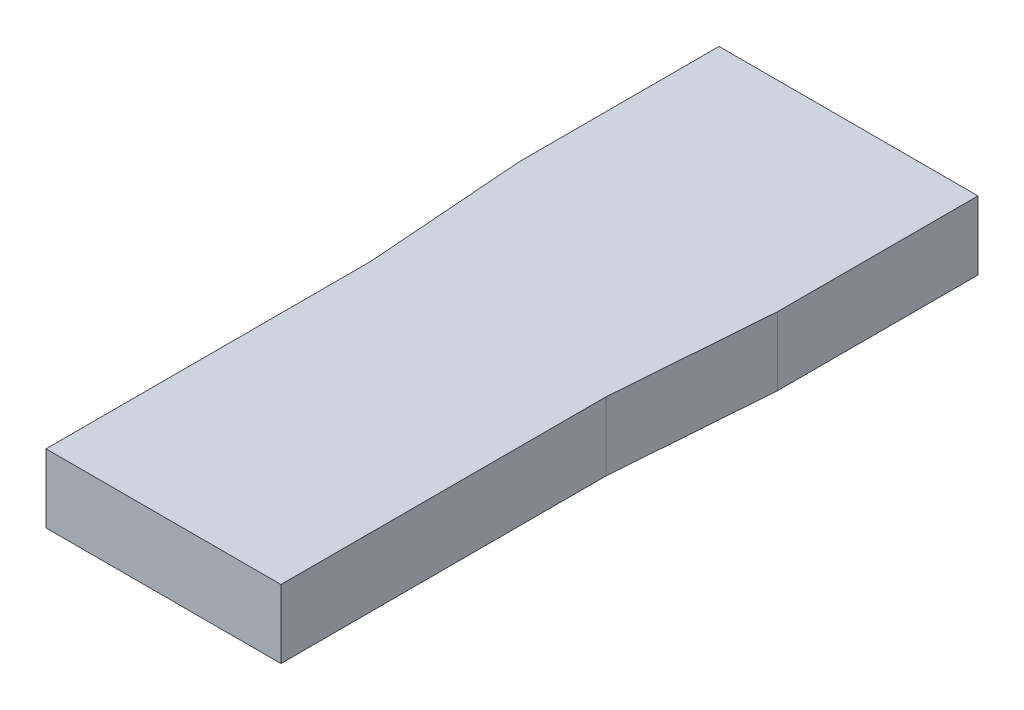
from build123d import *

# Parameters (mm, degrees)
SKETCH1_W           = 11.34
SKETCH1_H           = 30
BOSS_EXTRUDE1_DEPTH = 3
CUT_EXTRUDE1_START  = -4
CUT_EXTRUDE1_DEPTH  = 5


with BuildPart() as part:
    # Sketch1 → Boss-Extrude1 (new body)
    with BuildSketch(Plane(origin=(0, 0, 0), x_dir=(1, 0, 0), z_dir=(0, 1, 0))):
        Rectangle(SKETCH1_W, SKETCH1_H)
    extrude(amount=BOSS_EXTRUDE1_DEPTH)

    # Sketch2 → Cut-Extrude1 (cut)
    with BuildSketch(Plane(origin=(0, 3, 0), x_dir=(1, 0, 0), z_dir=(0, 1, 0)).offset(CUT_EXTRUDE1_START)):
        Polygon((-5.145, -15), (-5.145, -0.77), (-5.67, 6.23), (-5.67, -15), align=None)
    cut_extrude1 = extrude(amount=CUT_EXTRUDE1_DEPTH, mode=Mode.SUBTRACT)

    # Mirror1: Cut-Extrude1 across plane
    add(cut_extrude1.mirror(Plane(origin=(0, 0, 0), x_dir=(0, 0, 1), z_dir=(1, 0, 0))), mode=Mode.SUBTRACT)


solid = part.part
